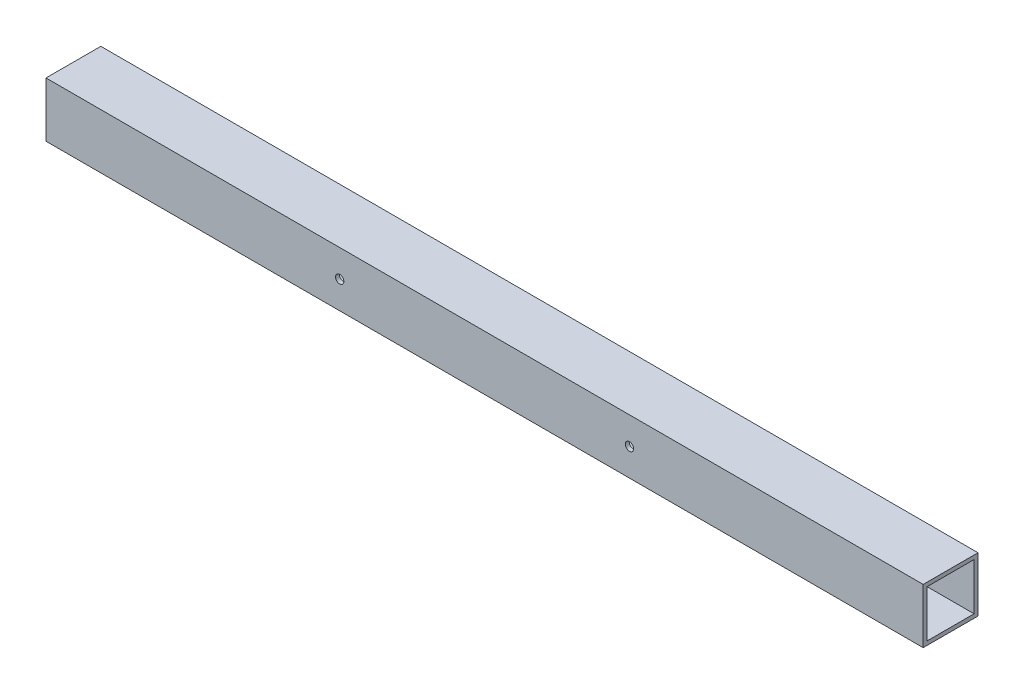
from build123d import *

# Parameters (mm, degrees)
SKETCH1_W                        = 44.45
SKETCH1_H                        = 44.45
SKETCH1_W_2                      = 38.1
SKETCH1_H_2                      = 38.1
BOSS_EXTRUDE1_DEPTH              = 355.6
BOSS_EXTRUDE1_DEPTH_BACK         = 355.6
F_17_64_0_26563_DIAMETER_HOLE1_D = 6.747002


with BuildPart() as part:
    # Sketch1 → Boss-Extrude1 (new body, two sides)
    with BuildSketch(Plane(origin=(0, 0, 0), x_dir=(0, 0, -1), z_dir=(1, 0, 0))) as boss_extrude1_sk:
        Rectangle(SKETCH1_W, SKETCH1_H)
        Rectangle(SKETCH1_W_2, SKETCH1_H_2, mode=Mode.SUBTRACT)
    extrude(amount=BOSS_EXTRUDE1_DEPTH)
    extrude(boss_extrude1_sk.sketch, amount=-BOSS_EXTRUDE1_DEPTH_BACK)

    # 17/64 (0.26563) Diameter Hole1 (through all)
    with Locations(Plane.XY.offset(22.225)):
        with Locations((-117.475, 0), (117.475, 0)):
            Hole(F_17_64_0_26563_DIAMETER_HOLE1_D / 2)


solid = part.part
